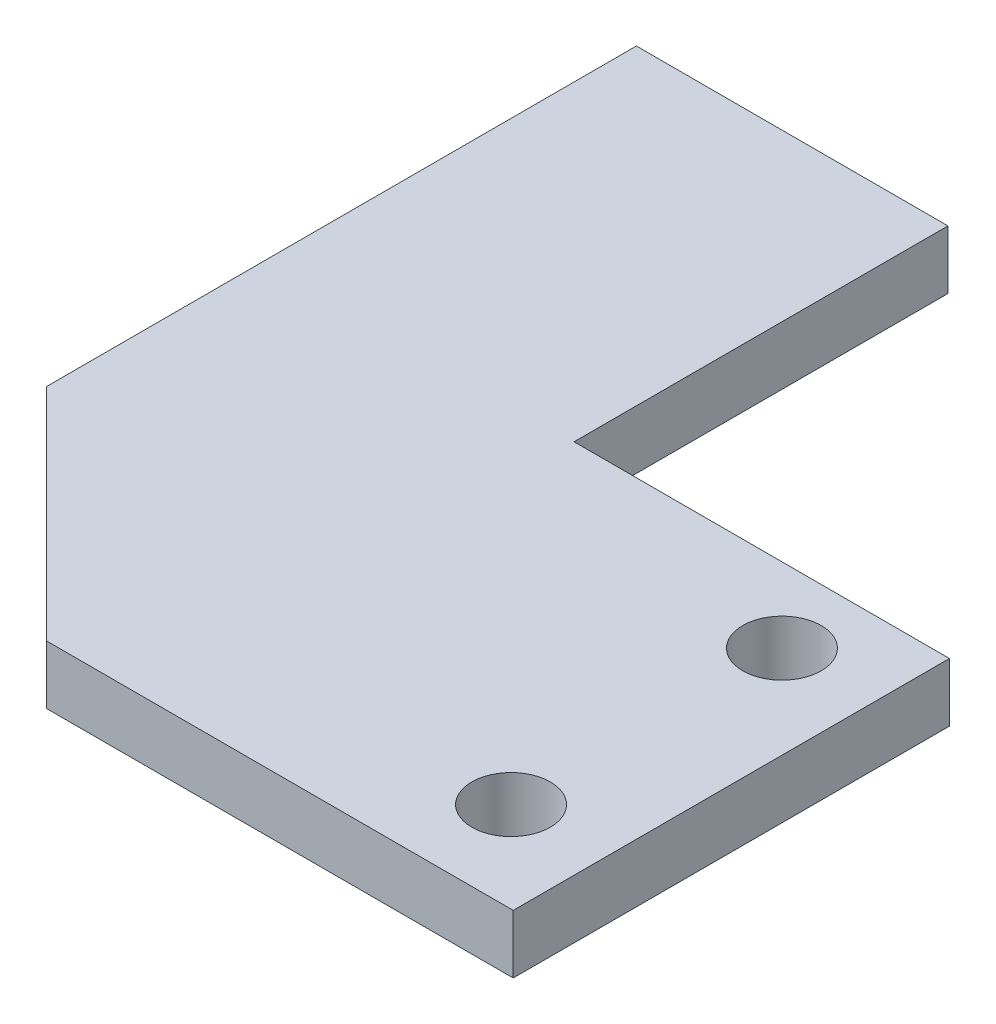
from build123d import *

# Parameters (mm, degrees)
SKETCH1_W           = 70
SKETCH1_H           = 44.45
SKETCH1_R           = 4
BOSS_EXTRUDE1_DEPTH = 5.969
SKETCH2_W           = 31.75
SKETCH2_H           = 38.1
BOSS_EXTRUDE3_DEPTH = 5.969
CUT_EXTRUDE1_DEPTH  = 6.969


with BuildPart() as part:
    # Sketch1 → Boss-Extrude1 (new body)
    with BuildSketch(Plane(origin=(0, 0, 0), x_dir=(1, 0, 0), z_dir=(0, 1, 0))):
        with Locations((35, 22.225)):
            Rectangle(SKETCH1_W, SKETCH1_H)
        with Locations((60.55391, 36.83)):
            Circle(SKETCH1_R, mode=Mode.SUBTRACT)
        with Locations((60.55391, 9.2261)):
            Circle(SKETCH1_R, mode=Mode.SUBTRACT)
    extrude(amount=BOSS_EXTRUDE1_DEPTH)

    # Sketch2 → Boss-Extrude3 (add)
    with BuildSketch(Plane(origin=(0, 5.969, 0), x_dir=(1, 0, 0), z_dir=(0, 1, 0))):
        with Locations((15.875, 63.5)):
            Rectangle(SKETCH2_W, SKETCH2_H)
    extrude(amount=-BOSS_EXTRUDE3_DEPTH)

    # Sketch3 → Cut-Extrude1 (cut, through all)
    with BuildSketch(Plane(origin=(0, 5.969, 0), x_dir=(1, 0, 0), z_dir=(0, 1, 0))):
        Polygon((0, 22.450640303), (22.450640303, 0), (0, 0), align=None)
    extrude(amount=-CUT_EXTRUDE1_DEPTH, mode=Mode.SUBTRACT)


solid = part.part
